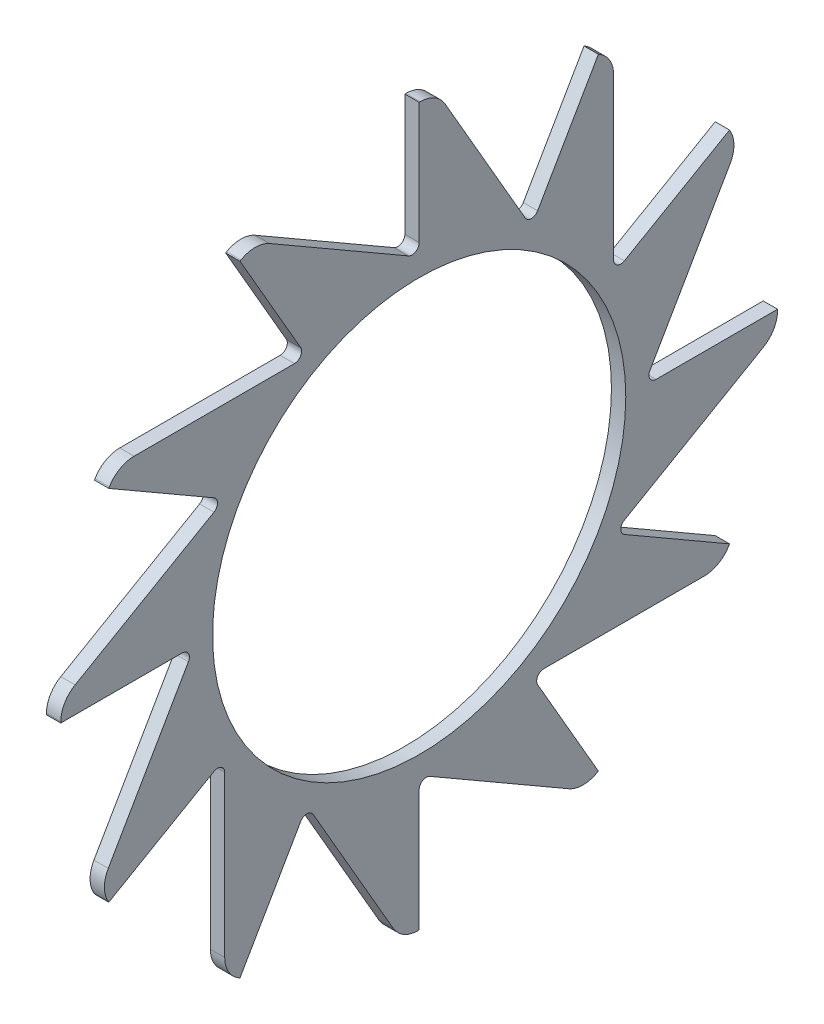
from build123d import *

# Parameters (mm, degrees)
ESQUISSE10_R                       = 100
ESQUISSE10_R_2                     = 57.65
BOSS_EXTRU_1_DEPTH                 = 2
ENL_V_MAT_EXTRU_3_DEPTH            = 3
CONG_3_R                           = 8
CONG_4_R                           = 2
R_P_TITION_CIRCULAIRE4_COUNT       = 12
CONG_3_OF_R_P_TITION_CIRCULAIRE4_R = 8
CONG_4_OF_R_P_TITION_CIRCULAIRE4_R = 2


with BuildPart() as part:
    # Esquisse10 → Boss.-Extru.1 (new body, symmetric)
    with BuildSketch(Plane(origin=(0, 0, 0), x_dir=(0, 0, -1), z_dir=(1, 0, 0))):
        Circle(ESQUISSE10_R)
        Circle(ESQUISSE10_R_2, mode=Mode.SUBTRACT)
    extrude(amount=BOSS_EXTRU_1_DEPTH, both=True)

    # Esquisse11 → Enlèv. mat.-Extru.3 (cut, symmetric)
    with BuildSketch(Plane(origin=(0, 0, 0), x_dir=(0, 0, -1), z_dir=(1, 0, 0))):
        Polygon((-467.515801905, 332.57037408), (-45.619089874, 88.988193819), (0, 62.65), (0, 100), (0, 587.164360523), (-465.974399707, 1442.842054211), (-933.490201612, 1188.248067768), align=None)
    enl_v_mat_extru_3 = extrude(amount=ENL_V_MAT_EXTRU_3_DEPTH, both=True, mode=Mode.SUBTRACT)

    # Congé3
    cong_3_edges = [part.edges().sort_by_distance(p)[0] for p in [
        (0, 88.988193819, 45.619089874),
    ]]
    fillet(cong_3_edges, radius=CONG_3_R)

    # Congé4
    cong_4_edges = [part.edges().sort_by_distance(p)[0] for p in [
        (0, 62.65, 0),
    ]]
    fillet(cong_4_edges, radius=CONG_4_R)

    # Répétition circulaire4: Enlèv. mat.-Extru.3 ×12 about axis
    r_p_tition_circulaire4_axis = Axis((0, 0, 0), (1, 0, 0))
    for i in range(1, R_P_TITION_CIRCULAIRE4_COUNT):
        add(enl_v_mat_extru_3.rotate(r_p_tition_circulaire4_axis, i * 360 / R_P_TITION_CIRCULAIRE4_COUNT), mode=Mode.SUBTRACT)

    # Congé3 of Répétition circulaire4
    cong_3_of_r_p_tition_circulaire4_edges = [part.edges().sort_by_distance(p)[0] for p in [
        (0, 54.256491547, 84.001387637),
        (0, 4.986806181, 99.875581421),
        (0, -45.619089874, 88.988193819),
        (0, -84.001387637, 54.256491547),
        (0, -99.875581421, 4.986806181),
        (0, -88.988193819, -45.619089874),
        (0, -54.256491547, -84.001387637),
        (0, -4.986806181, -99.875581421),
        (0, 45.619089874, -88.988193819),
        (0, 84.001387637, -54.256491547),
        (0, 99.875581421, -4.986806181),
    ]]
    fillet(cong_3_of_r_p_tition_circulaire4_edges, radius=CONG_3_OF_R_P_TITION_CIRCULAIRE4_R)

    # Congé4 of Répétition circulaire4
    cong_4_of_r_p_tition_circulaire4_edges = [part.edges().sort_by_distance(p)[0] for p in [
        (0, 54.256491547, 31.325),
        (0, 31.325, 54.256491547),
        (0, 0, 62.65),
        (0, -31.325, 54.256491547),
        (0, -54.256491547, 31.325),
        (0, -62.65, 0),
        (0, -54.256491547, -31.325),
        (0, -31.325, -54.256491547),
        (0, 0, -62.65),
        (0, 31.325, -54.256491547),
        (0, 54.256491547, -31.325),
    ]]
    fillet(cong_4_of_r_p_tition_circulaire4_edges, radius=CONG_4_OF_R_P_TITION_CIRCULAIRE4_R)


solid = part.part
